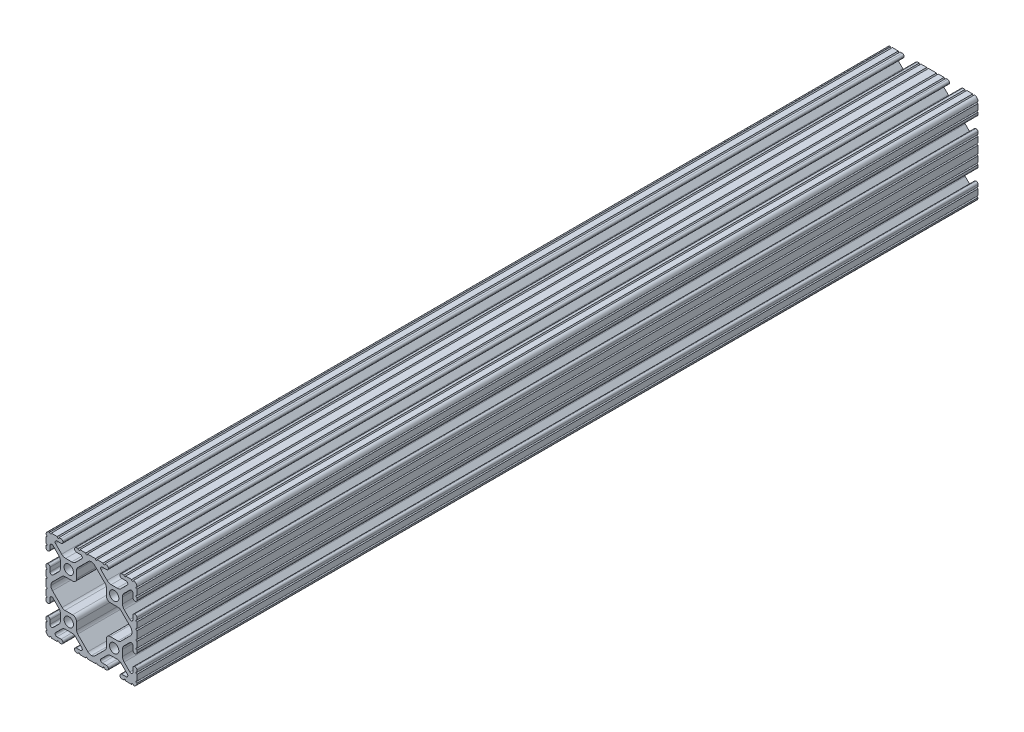
from build123d import *

# Parameters (mm, degrees)
SKETCH1_R      = 2.6035
EXTRUDE1_DEPTH = 235


with BuildPart() as part:
    # Sketch1 → Extrude1 (new body, symmetric)
    with BuildSketch(Plane.XY):
        with BuildLine():
            Line((7.457926116, -25.399784799), (8.405129993, -25.399784799))
            ThreePointArc((8.405129993, -25.399784799), (9.151169147, -25.100147214), (9.461499999, -24.358492401))
            Line((9.461499999, -24.358492401), (9.461499999, -24.231492401))
            ThreePointArc((9.461499999, -24.231492401), (9.151169154, -23.489837595), (8.405130015, -23.190200002))
            Line((8.405130015, -23.190200002), (6.087754001, -23.190200002))
            ThreePointArc((6.087754001, -23.190200002), (5.173448618, -22.579280676), (5.387974957, -21.500783942))
            Line((5.387974957, -21.500783942), (8.763022929, -18.12573597))
            ThreePointArc((8.763022929, -18.12573597), (9.793067061, -17.437482485), (11.008086958, -17.195800001))
            Line((11.008086958, -17.195800001), (14.391913039, -17.195800001))
            ThreePointArc((14.391913039, -17.195800001), (15.606932936, -17.437482485), (16.636977069, -18.12573597))
            Line((16.636977069, -18.12573597), (20.01202504, -21.500783942))
            ThreePointArc((20.01202504, -21.500783942), (20.223734166, -22.586011736), (19.297652816, -23.190092401))
            Line((19.297652816, -23.190092401), (16.979899998, -23.190092401))
            ThreePointArc((16.979899998, -23.190092401), (16.243518996, -23.495111399), (15.938499998, -24.231492401))
            Line((15.938499998, -24.231492401), (15.938499998, -24.358492401))
            ThreePointArc((15.938499998, -24.358492401), (16.248830851, -25.100147214), (16.994870004, -25.399784799))
            Line((16.994870004, -25.399784799), (18.13401566, -25.399784799))
            ThreePointArc((18.13401566, -25.399784799), (18.636212386, -24.81521817), (19.138409112, -25.399784799))
            Line((19.138409112, -25.399784799), (22.413213188, -25.399784799))
            ThreePointArc((22.413213188, -25.399784799), (22.915409914, -24.815218171), (23.41760664, -25.399784799))
            Line((23.41760664, -25.399784799), (23.450078699, -25.399784799))
            ThreePointArc((23.450078699, -25.399784799), (24.83746982, -24.731205619), (25.399999998, -23.297534792))
            Line((25.399999998, -23.297534792), (25.399999998, -23.268649528))
            ThreePointArc((25.399999998, -23.268649528), (24.891999998, -22.760649528), (25.399999998, -22.252649528))
            Line((25.399999998, -22.252649528), (25.399999998, -19.025239356))
            ThreePointArc((25.399999998, -19.025239356), (24.891999998, -18.517239356), (25.399999998, -18.009239356))
            Line((25.399999998, -18.009239356), (25.399999998, -16.916041811))
            ThreePointArc((25.399999998, -16.916041811), (25.094981, -16.179660809), (24.358599998, -15.874641811))
            Line((24.358599998, -15.874641811), (24.231599998, -15.874641811))
            ThreePointArc((24.231599998, -15.874641811), (23.495218996, -16.179660809), (23.190199998, -16.916041811))
            Line((23.190199998, -16.916041811), (23.190199998, -19.10098879))
            ThreePointArc((23.190199998, -19.10098879), (22.563006365, -20.039650395), (21.455779508, -19.81940928))
            Line((21.455779508, -19.81940928), (18.278135968, -16.641765739))
            ThreePointArc((18.278135968, -16.641765739), (17.589882482, -15.611721607), (17.348199998, -14.396701709))
            Line((17.348199998, -14.396701709), (17.348199998, -11.003495044))
            ThreePointArc((17.348199998, -11.003495044), (17.59061076, -9.786718416), (18.280826998, -8.755743205))
            Line((18.280826998, -8.755743205), (21.456640638, -5.587529243))
            ThreePointArc((21.456640638, -5.587529243), (22.563568519, -5.368381276), (23.190199998, -6.306809832))
            Line((23.190199998, -6.306809832), (23.190199998, -8.483958193))
            ThreePointArc((23.190199998, -8.483958193), (23.495218996, -9.220339195), (24.231599998, -9.525358193))
            Line((24.231599998, -9.525358193), (24.358599998, -9.525358193))
            ThreePointArc((24.358599998, -9.525358193), (25.094981, -9.220339195), (25.399999998, -8.483958193))
            Line((25.399999998, -8.483958193), (25.399999998, -7.327686688))
            ThreePointArc((25.399999998, -7.327686688), (24.891999998, -6.819686688), (25.399999998, -6.311686688))
            Line((25.399999998, -6.311686688), (25.399999998, -3.084276516))
            ThreePointArc((25.399999998, -3.084276516), (24.891999998, -2.576276516), (25.399999998, -2.068276516))
            Line((25.399999998, -2.068276516), (25.399999998, 2.068276512))
            ThreePointArc((25.399999998, 2.068276512), (24.891999998, 2.576276512), (25.399999998, 3.084276512))
            Line((25.399999998, 3.084276512), (25.399999998, 6.311686684))
            ThreePointArc((25.399999998, 6.311686684), (24.891999998, 6.819686684), (25.399999998, 7.327686684))
            Line((25.399999998, 7.327686684), (25.399999998, 8.483958189))
            ThreePointArc((25.399999998, 8.483958189), (25.094981, 9.220339191), (24.358599998, 9.525358189))
            Line((24.358599998, 9.525358189), (24.231599998, 9.525358189))
            ThreePointArc((24.231599998, 9.525358189), (23.495218996, 9.220339191), (23.190199998, 8.483958189))
            Line((23.190199998, 8.483958189), (23.190199998, 6.306809828))
            ThreePointArc((23.190199998, 6.306809828), (22.563568519, 5.368381272), (21.456640638, 5.58752924))
            Line((21.456640638, 5.58752924), (18.280826998, 8.755743201))
            ThreePointArc((18.280826998, 8.755743201), (17.59061076, 9.786718412), (17.348199998, 11.00349504))
            Line((17.348199998, 11.00349504), (17.348199998, 14.396701706))
            ThreePointArc((17.348199998, 14.396701706), (17.589882482, 15.611721603), (18.278135968, 16.641765736))
            Line((18.278135968, 16.641765736), (21.455779508, 19.819409276))
            ThreePointArc((21.455779508, 19.819409276), (22.563006365, 20.039650391), (23.190199998, 19.100988787))
            Line((23.190199998, 19.100988787), (23.190199998, 16.916041808))
            ThreePointArc((23.190199998, 16.916041808), (23.495218996, 16.179660806), (24.231599998, 15.874641808))
            Line((24.231599998, 15.874641808), (24.358599998, 15.874641808))
            ThreePointArc((24.358599998, 15.874641808), (25.094981, 16.179660806), (25.399999998, 16.916041808))
            Line((25.399999998, 16.916041808), (25.399999998, 18.009239352))
            ThreePointArc((25.399999998, 18.009239352), (24.891999998, 18.517239352), (25.399999998, 19.025239352))
            Line((25.399999998, 19.025239352), (25.399999998, 22.252649524))
            ThreePointArc((25.399999998, 22.252649524), (24.891999998, 22.760649524), (25.399999998, 23.268649524))
            Line((25.399999998, 23.268649524), (25.399999998, 23.297534788))
            ThreePointArc((25.399999998, 23.297534788), (24.837469823, 24.731205612), (23.450078707, 25.399784795))
            Line((23.450078707, 25.399784795), (23.417606647, 25.399784795))
            ThreePointArc((23.417606647, 25.399784795), (22.915409918, 24.81521819), (22.413213188, 25.399784795))
            Line((22.413213188, 25.399784795), (19.138409112, 25.399784795))
            ThreePointArc((19.138409112, 25.399784795), (18.636212386, 24.815218167), (18.13401566, 25.399784795))
            Line((18.13401566, 25.399784795), (16.994870004, 25.399784795))
            ThreePointArc((16.994870004, 25.399784795), (16.248830851, 25.100147209), (15.938499998, 24.358492396))
            Line((15.938499998, 24.358492396), (15.938499998, 24.231492396))
            ThreePointArc((15.938499998, 24.231492396), (16.243518996, 23.495111394), (16.979899998, 23.190092396))
            Line((16.979899998, 23.190092396), (19.297652816, 23.190092396))
            ThreePointArc((19.297652816, 23.190092396), (20.223734166, 22.586011731), (20.01202504, 21.500783938))
            Line((20.01202504, 21.500783938), (16.636977069, 18.125735966))
            ThreePointArc((16.636977069, 18.125735966), (15.606932936, 17.437482481), (14.391913039, 17.195799997))
            Line((14.391913039, 17.195799997), (11.008086958, 17.195799997))
            ThreePointArc((11.008086958, 17.195799997), (9.793067061, 17.437482481), (8.763022929, 18.125735966))
            Line((8.763022929, 18.125735966), (5.387974957, 21.500783938))
            ThreePointArc((5.387974957, 21.500783938), (5.173448618, 22.579280672), (6.087754001, 23.190199998))
            Line((6.087754001, 23.190199998), (8.405130015, 23.190199998))
            ThreePointArc((8.405130015, 23.190199998), (9.151169154, 23.48983759), (9.461499999, 24.231492396))
            Line((9.461499999, 24.231492396), (9.461499999, 24.358492396))
            ThreePointArc((9.461499999, 24.358492396), (9.151169147, 25.10014721), (8.405129993, 25.399784795))
            Line((8.405129993, 25.399784795), (7.457926116, 25.399784795))
            ThreePointArc((7.457926116, 25.399784795), (6.95572939, 24.815218166), (6.453532664, 25.399784795))
            Line((6.453532664, 25.399784795), (3.214515944, 25.399784795))
            ThreePointArc((3.214515944, 25.399784795), (2.712319218, 24.815218166), (2.210122492, 25.399784795))
            Line((2.210122492, 25.399784795), (-2.210122494, 25.399784795))
            ThreePointArc((-2.210122494, 25.399784795), (-2.71231922, 24.815218166), (-3.214515945, 25.399784795))
            Line((-3.214515945, 25.399784795), (-6.453532666, 25.399784795))
            ThreePointArc((-6.453532666, 25.399784795), (-6.955729392, 24.815218166), (-7.457926117, 25.399784795))
            Line((-7.457926117, 25.399784795), (-8.405129995, 25.399784795))
            ThreePointArc((-8.405129995, 25.399784795), (-9.151169148, 25.10014721), (-9.461500001, 24.358492396))
            Line((-9.461500001, 24.358492396), (-9.461500001, 24.231492396))
            ThreePointArc((-9.461500001, 24.231492396), (-9.151169155, 23.48983759), (-8.405130016, 23.190199998))
            Line((-8.405130016, 23.190199998), (-6.087754002, 23.190199998))
            ThreePointArc((-6.087754002, 23.190199998), (-5.173448619, 22.579280672), (-5.387974958, 21.500783938))
            Line((-5.387974958, 21.500783938), (-8.76302293, 18.125735966))
            ThreePointArc((-8.76302293, 18.125735966), (-9.793067062, 17.437482481), (-11.00808696, 17.195799997))
            Line((-11.00808696, 17.195799997), (-14.39191304, 17.195799997))
            ThreePointArc((-14.39191304, 17.195799997), (-15.606932938, 17.437482481), (-16.63697707, 18.125735966))
            Line((-16.63697707, 18.125735966), (-20.012025042, 21.500783938))
            ThreePointArc((-20.012025042, 21.500783938), (-20.223734167, 22.586011731), (-19.297652817, 23.190092396))
            Line((-19.297652817, 23.190092396), (-16.979899999, 23.190092396))
            ThreePointArc((-16.979899999, 23.190092396), (-16.243518997, 23.495111394), (-15.938499999, 24.231492396))
            Line((-15.938499999, 24.231492396), (-15.938499999, 24.358492396))
            ThreePointArc((-15.938499999, 24.358492396), (-16.248830852, 25.100147209), (-16.994870005, 25.399784795))
            Line((-16.994870005, 25.399784795), (-18.134015662, 25.399784795))
            ThreePointArc((-18.134015662, 25.399784795), (-18.636212391, 24.815218189), (-19.13840912, 25.399784795))
            Line((-19.13840912, 25.399784795), (-22.413213196, 25.399784795))
            ThreePointArc((-22.413213196, 25.399784795), (-22.915409922, 24.815218167), (-23.417606648, 25.399784795))
            Line((-23.417606648, 25.399784795), (-23.450078708, 25.399784795))
            ThreePointArc((-23.450078708, 25.399784795), (-24.837469824, 24.731205612), (-25.399999999, 23.297534788))
            Line((-25.399999999, 23.297534788), (-25.399999999, 23.268649524))
            ThreePointArc((-25.399999999, 23.268649524), (-24.891999999, 22.760649524), (-25.399999999, 22.252649524))
            Line((-25.399999999, 22.252649524), (-25.399999999, 19.025239352))
            ThreePointArc((-25.399999999, 19.025239352), (-24.891999999, 18.517239352), (-25.399999999, 18.009239352))
            Line((-25.399999999, 18.009239352), (-25.399999999, 16.916041808))
            ThreePointArc((-25.399999999, 16.916041808), (-25.094981001, 16.179660806), (-24.358599999, 15.874641808))
            Line((-24.358599999, 15.874641808), (-24.231599999, 15.874641808))
            ThreePointArc((-24.231599999, 15.874641808), (-23.495218997, 16.179660806), (-23.190199999, 16.916041808))
            Line((-23.190199999, 16.916041808), (-23.190199999, 19.100988787))
            ThreePointArc((-23.190199999, 19.100988787), (-22.563006366, 20.039650391), (-21.45577951, 19.819409276))
            Line((-21.45577951, 19.819409276), (-18.278135969, 16.641765736))
            ThreePointArc((-18.278135969, 16.641765736), (-17.589882484, 15.611721603), (-17.348199999, 14.396701706))
            Line((-17.348199999, 14.396701706), (-17.348199999, 11.00349504))
            ThreePointArc((-17.348199999, 11.00349504), (-17.590610762, 9.786718412), (-18.280826999, 8.755743201))
            Line((-18.280826999, 8.755743201), (-21.456640639, 5.58752924))
            ThreePointArc((-21.456640639, 5.58752924), (-22.56356852, 5.368381272), (-23.190199999, 6.306809828))
            Line((-23.190199999, 6.306809828), (-23.190199999, 8.483958189))
            ThreePointArc((-23.190199999, 8.483958189), (-23.495218997, 9.220339191), (-24.231599999, 9.525358189))
            Line((-24.231599999, 9.525358189), (-24.358599999, 9.525358189))
            ThreePointArc((-24.358599999, 9.525358189), (-25.094981001, 9.220339191), (-25.399999999, 8.483958189))
            Line((-25.399999999, 8.483958189), (-25.399999999, 7.327686684))
            ThreePointArc((-25.399999999, 7.327686684), (-24.891999999, 6.819686684), (-25.399999999, 6.311686684))
            Line((-25.399999999, 6.311686684), (-25.399999999, 3.084276512))
            ThreePointArc((-25.399999999, 3.084276512), (-24.891999999, 2.576276512), (-25.399999999, 2.068276512))
            Line((-25.399999999, 2.068276512), (-25.399999999, -2.068276516))
            ThreePointArc((-25.399999999, -2.068276516), (-24.891999999, -2.576276516), (-25.399999999, -3.084276516))
            Line((-25.399999999, -3.084276516), (-25.399999999, -6.311686688))
            ThreePointArc((-25.399999999, -6.311686688), (-24.891999999, -6.819686688), (-25.399999999, -7.327686688))
            Line((-25.399999999, -7.327686688), (-25.399999999, -8.483958193))
            ThreePointArc((-25.399999999, -8.483958193), (-25.094981001, -9.220339195), (-24.358599999, -9.525358193))
            Line((-24.358599999, -9.525358193), (-24.231599999, -9.525358193))
            ThreePointArc((-24.231599999, -9.525358193), (-23.495218997, -9.220339195), (-23.190199999, -8.483958193))
            Line((-23.190199999, -8.483958193), (-23.190199999, -6.306809832))
            ThreePointArc((-23.190199999, -6.306809832), (-22.56356852, -5.368381276), (-21.456640639, -5.587529243))
            Line((-21.456640639, -5.587529243), (-18.280826999, -8.755743205))
            ThreePointArc((-18.280826999, -8.755743205), (-17.590610762, -9.786718416), (-17.348199999, -11.003495044))
            Line((-17.348199999, -11.003495044), (-17.348199999, -14.396701709))
            ThreePointArc((-17.348199999, -14.396701709), (-17.589882484, -15.611721607), (-18.278135969, -16.641765739))
            Line((-18.278135969, -16.641765739), (-21.45577951, -19.81940928))
            ThreePointArc((-21.45577951, -19.81940928), (-22.563006366, -20.039650395), (-23.190199999, -19.10098879))
            Line((-23.190199999, -19.10098879), (-23.190199999, -16.916041811))
            ThreePointArc((-23.190199999, -16.916041811), (-23.495218997, -16.179660809), (-24.231599999, -15.874641811))
            Line((-24.231599999, -15.874641811), (-24.358599999, -15.874641811))
            ThreePointArc((-24.358599999, -15.874641811), (-25.094981001, -16.179660809), (-25.399999999, -16.916041811))
            Line((-25.399999999, -16.916041811), (-25.399999999, -18.009239356))
            ThreePointArc((-25.399999999, -18.009239356), (-24.891999999, -18.517239356), (-25.399999999, -19.025239356))
            Line((-25.399999999, -19.025239356), (-25.399999999, -22.252649528))
            ThreePointArc((-25.399999999, -22.252649528), (-24.891999999, -22.760649528), (-25.399999999, -23.268649528))
            Line((-25.399999999, -23.268649528), (-25.399999999, -23.297534792))
            ThreePointArc((-25.399999999, -23.297534792), (-24.837469821, -24.731205619), (-23.450078701, -25.399784799))
            Line((-23.450078701, -25.399784799), (-23.417606641, -25.399784799))
            ThreePointArc((-23.417606641, -25.399784799), (-22.915409915, -24.81521817), (-22.413213189, -25.399784799))
            Line((-22.413213189, -25.399784799), (-19.138409113, -25.399784799))
            ThreePointArc((-19.138409113, -25.399784799), (-18.636212388, -24.81521817), (-18.134015662, -25.399784799))
            Line((-18.134015662, -25.399784799), (-16.994870005, -25.399784799))
            ThreePointArc((-16.994870005, -25.399784799), (-16.248830852, -25.100147214), (-15.938499999, -24.358492401))
            Line((-15.938499999, -24.358492401), (-15.938499999, -24.231492401))
            ThreePointArc((-15.938499999, -24.231492401), (-16.243518997, -23.495111399), (-16.979899999, -23.190092401))
            Line((-16.979899999, -23.190092401), (-19.297652817, -23.190092401))
            ThreePointArc((-19.297652817, -23.190092401), (-20.223734167, -22.586011736), (-20.012025042, -21.500783942))
            Line((-20.012025042, -21.500783942), (-16.63697707, -18.12573597))
            ThreePointArc((-16.63697707, -18.12573597), (-15.606932938, -17.437482485), (-14.39191304, -17.195800001))
            Line((-14.39191304, -17.195800001), (-11.00808696, -17.195800001))
            ThreePointArc((-11.00808696, -17.195800001), (-9.793067062, -17.437482485), (-8.76302293, -18.12573597))
            Line((-8.76302293, -18.12573597), (-5.387974958, -21.500783942))
            ThreePointArc((-5.387974958, -21.500783942), (-5.173448619, -22.579280676), (-6.087754002, -23.190200002))
            Line((-6.087754002, -23.190200002), (-8.405130016, -23.190200002))
            ThreePointArc((-8.405130016, -23.190200002), (-9.151169155, -23.489837595), (-9.461500001, -24.231492401))
            Line((-9.461500001, -24.231492401), (-9.461500001, -24.358492401))
            ThreePointArc((-9.461500001, -24.358492401), (-9.151169148, -25.100147214), (-8.405129995, -25.399784799))
            Line((-8.405129995, -25.399784799), (-7.457926117, -25.399784799))
            ThreePointArc((-7.457926117, -25.399784799), (-6.955729392, -24.81521817), (-6.453532666, -25.399784799))
            Line((-6.453532666, -25.399784799), (-3.214515945, -25.399784799))
            ThreePointArc((-3.214515945, -25.399784799), (-2.71231922, -24.81521817), (-2.210122494, -25.399784799))
            Line((-2.210122494, -25.399784799), (2.210122492, -25.399784799))
            ThreePointArc((2.210122492, -25.399784799), (2.712319218, -24.81521817), (3.214515944, -25.399784799))
            Line((3.214515944, -25.399784799), (6.453532664, -25.399784799))
            ThreePointArc((6.453532664, -25.399784799), (6.95572939, -24.815218171), (7.457926116, -25.399784799))
        make_face()
        with Locations((12.7, 12.7)):
            Circle(SKETCH1_R, mode=Mode.SUBTRACT)
        with Locations((-12.7, 12.7)):
            Circle(SKETCH1_R, mode=Mode.SUBTRACT)
        with Locations((-12.7, -12.7)):
            Circle(SKETCH1_R, mode=Mode.SUBTRACT)
        with Locations((12.7, -12.7)):
            Circle(SKETCH1_R, mode=Mode.SUBTRACT)
        with BuildLine():
            Line((-7.683964565, -16.079665203), (-1.987770861, -21.775858907))
            ThreePointArc((-1.987770861, -21.775858907), (-1.075921771, -22.393947165), (0, -22.630366706))
            ThreePointArc((0, -22.630366706), (1.07592177, -22.393947165), (1.98777086, -21.775858907))
            Line((1.98777086, -21.775858907), (7.683964564, -16.079665203))
            ThreePointArc((7.683964564, -16.079665203), (8.16298899, -15.362754487), (8.331199999, -14.517100638))
            Line((8.331199999, -14.517100638), (8.331199999, -10.3886))
            ThreePointArc((8.331199999, -10.3886), (8.978435434, -8.826035435), (10.540999999, -8.1788))
            Line((10.540999999, -8.1788), (14.816495759, -8.1788))
            ThreePointArc((14.816495759, -8.1788), (15.66092662, -8.01109514), (16.377187367, -7.53343528))
            Line((16.377187367, -7.53343528), (21.773383159, -2.150152509))
            ThreePointArc((21.773383159, -2.150152509), (22.408382098, -1.201655315), (22.631399999, -0.082220817))
            Line((22.631399999, -0.082220817), (22.631399999, 0.082220818))
            ThreePointArc((22.631399999, 0.082220818), (22.408382098, 1.201655315), (21.773383159, 2.150152509))
            Line((21.773383159, 2.150152509), (16.376754094, 7.533867516))
            ThreePointArc((16.376754094, 7.533867516), (15.660493348, 8.011527376), (14.816062486, 8.179232236))
            Line((14.816062486, 8.179232236), (10.540999999, 8.179232236))
            ThreePointArc((10.540999999, 8.179232236), (8.978435434, 8.826467671), (8.331199999, 10.389032236))
            Line((8.331199999, 10.389032236), (8.331199999, 14.517100641))
            ThreePointArc((8.331199999, 14.517100641), (8.16298899, 15.362754489), (7.683964564, 16.079665206))
            Line((7.683964564, 16.079665206), (1.795557488, 21.968072282))
            ThreePointArc((1.795557488, 21.968072282), (0.971532486, 22.546678967), (1.3e-08, 22.811117151))
            ThreePointArc((1.3e-08, 22.811117151), (-0.971532474, 22.54667897), (-1.795557488, 21.96807228))
            Line((-1.795557488, 21.96807228), (-7.683964565, 16.079665203))
            ThreePointArc((-7.683964565, 16.079665203), (-8.162988991, 15.362754487), (-8.3312, 14.517100638))
            Line((-8.3312, 14.517100638), (-8.3312, 10.3886))
            ThreePointArc((-8.3312, 10.3886), (-8.978435435, 8.826035435), (-10.541, 8.1788))
            Line((-10.541, 8.1788), (-14.816495759, 8.1788))
            ThreePointArc((-14.816495759, 8.1788), (-15.660926621, 8.01109514), (-16.377187367, 7.53343528))
            Line((-16.377187367, 7.53343528), (-21.77338316, 2.150152509))
            ThreePointArc((-21.77338316, 2.150152509), (-22.408382099, 1.201655315), (-22.6314, 0.082220817))
            Line((-22.6314, 0.082220817), (-22.6314, -0.082220817))
            ThreePointArc((-22.6314, -0.082220817), (-22.408382099, -1.201655315), (-21.77338316, -2.150152509))
            Line((-21.77338316, -2.150152509), (-16.377187367, -7.53343528))
            ThreePointArc((-16.377187367, -7.53343528), (-15.660926621, -8.01109514), (-14.816495759, -8.1788))
            Line((-14.816495759, -8.1788), (-10.541, -8.1788))
            ThreePointArc((-10.541, -8.1788), (-8.978435435, -8.826035435), (-8.3312, -10.3886))
            Line((-8.3312, -10.3886), (-8.3312, -14.517100638))
            ThreePointArc((-8.3312, -14.517100638), (-8.162988991, -15.362754487), (-7.683964565, -16.079665203))
        make_face(mode=Mode.SUBTRACT)
    extrude(amount=EXTRUDE1_DEPTH, both=True)


solid = part.part
